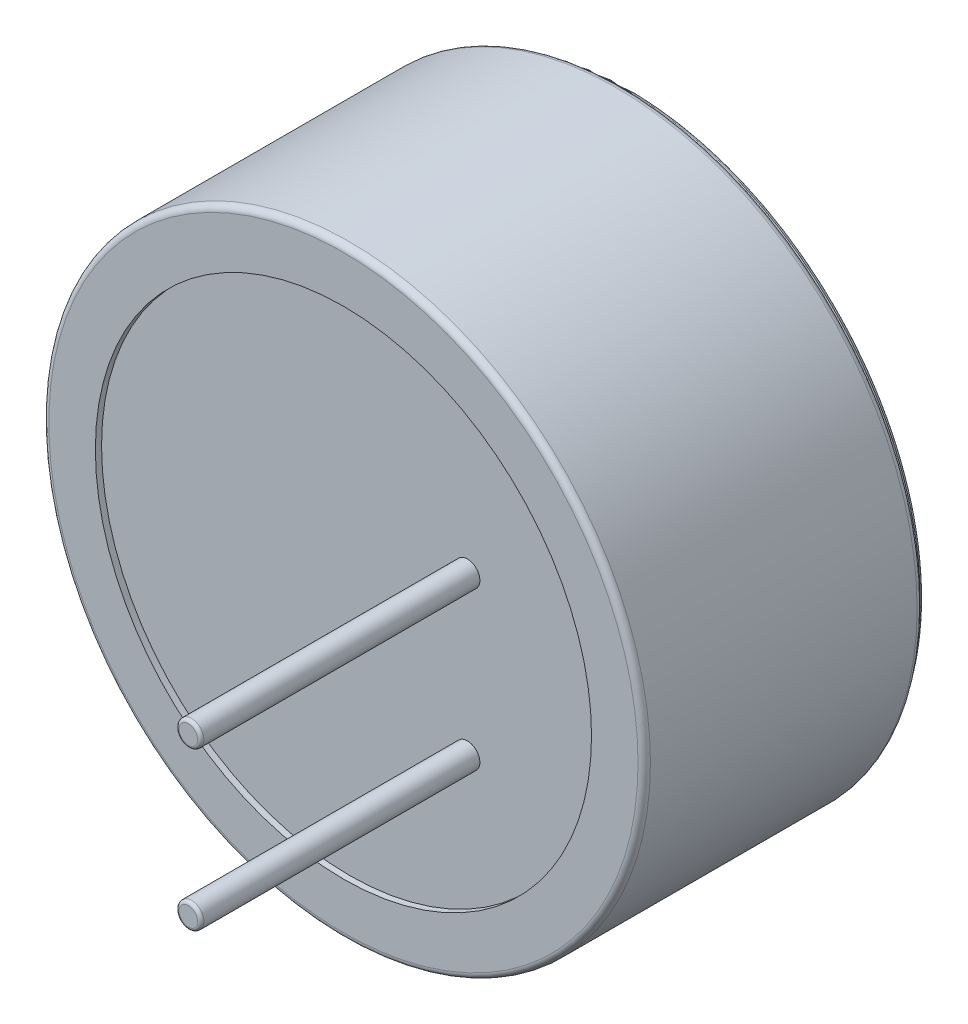
from build123d import *

# Parameters (mm, degrees)
SKETCH1_R             = 4.85
BOSS_EXTRUDE1_DEPTH   = 4.5
SKETCH3_R             = 0.2
BOSS_EXTRUDE2_DEPTH   = 4.5
BOSS_EXTRUDE2_2_DEPTH = 4.5
FILLET1_R             = 0.1
SKETCH4_R             = 4.75
BOSS_EXTRUDE3_DEPTH   = 0.1
FILLET2_R             = 0.05
SKETCH6_R             = 4
CUT_EXTRUDE1_DEPTH    = 0.1
FILLET3_R             = 0.05
FILLET4_R             = 0.05


with BuildPart() as part:
    # Sketch1 → Boss-Extrude1 (new body)
    with BuildSketch(Plane.XY):
        Circle(SKETCH1_R)
    extrude(amount=BOSS_EXTRUDE1_DEPTH)

    # Fillet1
    fillet1_edges = [part.edges().sort_by_distance(p)[0] for p in [
        (-4.85, 0, 0),
        (-4.85, 0, 4.5),
    ]]
    fillet(fillet1_edges, radius=FILLET1_R)

    # Sketch6 → Cut-Extrude1 (cut)
    with BuildSketch(Plane.XY.offset(4.5)):
        Circle(SKETCH6_R)
    extrude(amount=-CUT_EXTRUDE1_DEPTH, mode=Mode.SUBTRACT)


with BuildPart() as body_2:
    # Sketch3 → Boss-Extrude2 (new body)
    with BuildSketch(Plane.XY.offset(4.5)):
        with Locations((2, -1.27)):
            Circle(SKETCH3_R)
    extrude(amount=BOSS_EXTRUDE2_DEPTH)

    # Fillet3
    fillet3_edges = [body_2.edges().sort_by_distance(p)[0] for p in [
        (1.8, -1.27, 9),
    ]]
    fillet(fillet3_edges, radius=FILLET3_R)


with BuildPart() as body_3:
    # Sketch3 → Boss-Extrude2 2 (new body)
    with BuildSketch(Plane.XY.offset(4.5)):
        with Locations((2, 1.27)):
            Circle(SKETCH3_R)
    extrude(amount=BOSS_EXTRUDE2_2_DEPTH)

    # Fillet4
    fillet4_edges = [body_3.edges().sort_by_distance(p)[0] for p in [
        (1.8, 1.27, 9),
    ]]
    fillet(fillet4_edges, radius=FILLET4_R)


with BuildPart() as body_4:
    # Sketch4 → Boss-Extrude3 (new body)
    with BuildSketch(Plane(origin=(0, 0, 0), x_dir=(-1, 0, 0), z_dir=(0, 0, -1))):
        Circle(SKETCH4_R)
    extrude(amount=BOSS_EXTRUDE3_DEPTH)

    # Fillet2
    fillet2_edges = [body_4.edges().sort_by_distance(p)[0] for p in [
        (4.75, 0, -0.1),
    ]]
    fillet(fillet2_edges, radius=FILLET2_R)


solid = Compound([part.part, body_2.part, body_3.part, body_4.part])
